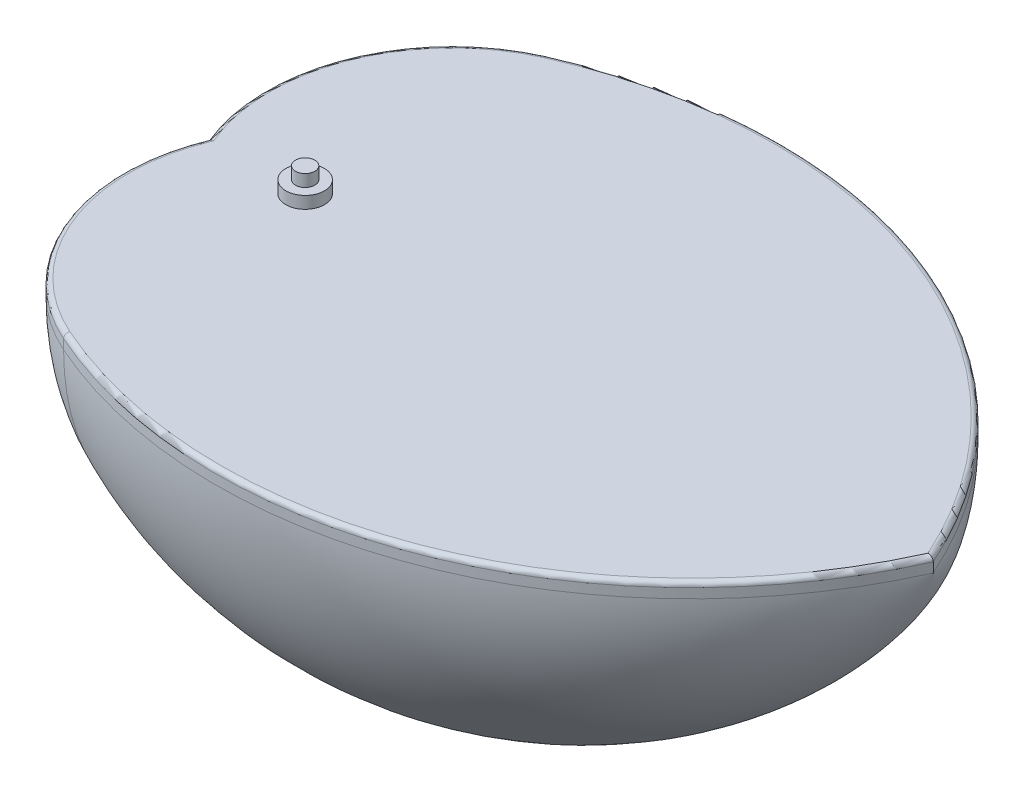
from build123d import *

# Parameters (mm, degrees)
REVOLVE1_ANGLE      = 180
BOSS_EXTRUDE1_DEPTH = 3
FILLET1_R           = 1


with BuildPart() as part:
    # Sketch1 → Revolve1 (revolve, symmetric)
    with BuildSketch(Plane.XY) as revolve1_sk:
        with BuildLine():
            Line((-20, 50), (-17, 50))
            ThreePointArc((-17, 50), (-18.335872201, 22.942344098), (0, 3))
            ThreePointArc((0, 3), (73.234018716, 0.197438789), (127, 50))
            Line((127, 50), (130, 50))
            ThreePointArc((130, 50), (75.355339059, -1.923881554), (0, 0))
            ThreePointArc((0, 0), (-20.16062326, 20.935750696), (-20, 50))
        make_face()
    revolve(axis=Axis((0, 50, 0), (-1, 0, 0)), revolution_arc=REVOLVE1_ANGLE / 2)
    revolve(revolve1_sk.sketch, axis=Axis((0, 50, 0), (1, 0, 0)), revolution_arc=REVOLVE1_ANGLE / 2)

    # Sketch2 → Boss-Extrude1 (add)
    with BuildSketch(Plane(origin=(0, 50, 0), x_dir=(1, 0, 0), z_dir=(0, 1, 0))):
        with BuildLine():
            ThreePointArc((-20, 0), (-20.16062326, -29.064249304), (0, -50))
            ThreePointArc((0, -50), (75.355339059, -51.923881554), (130, 0))
            ThreePointArc((130, 0), (75.355339059, 51.923881554), (0, 50))
            ThreePointArc((0, 50), (-20.16062326, 29.064249304), (-20, 0))
        make_face()
    extrude(amount=BOSS_EXTRUDE1_DEPTH)

    # Fillet1
    fillet1_edges = [part.edges().sort_by_distance(p)[0] for p in [
        (-20.16062326, 53, -29.064249304),
        (-20.16062326, 53, 29.064249304),
        (75.355339059, 53, 51.923881554),
        (75.355339059, 53, -51.923881554),
    ]]
    fillet(fillet1_edges, radius=FILLET1_R)

    # Sketch4 → Revolve2 (revolve)
    with BuildSketch(Plane(origin=(0, 0, 0), x_dir=(0, 0, -1), z_dir=(1, 0, 0))):
        Polygon((0, 53), (0, 58), (2, 58), (2, 55.5), (4, 55.5), (4, 53), align=None)
    revolve(axis=Axis((0, 53, 0), (0, 1, 0)))


solid = part.part
